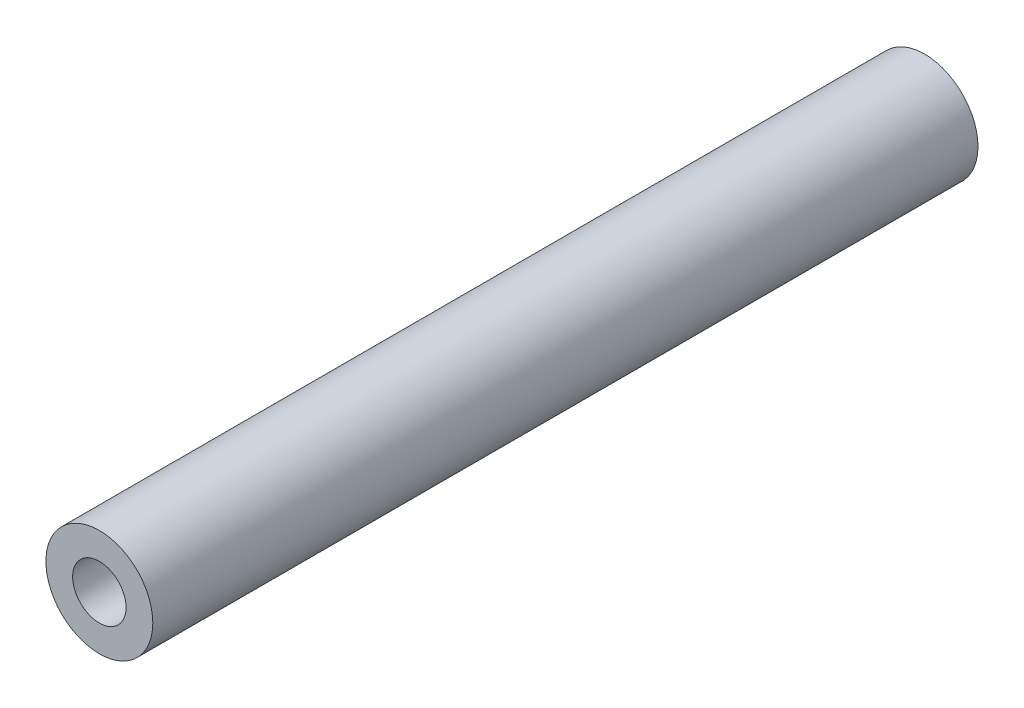
from build123d import *

# Parameters (mm, degrees)
SKETCH_6_R               = 2.5
EXTRUDE_2_DEPTH          = 19.3
M3X0_5_3_D               = 2.5
M3X0_5_3_DEPTH           = 8.5
M3X0_5_3_TIP             = 0.751075774
M3X0_5_3_ON_FACE_2_D     = 2.5
M3X0_5_3_ON_FACE_2_DEPTH = 8.5
M3X0_5_3_ON_FACE_2_TIP   = 0.751075774


with BuildPart() as part:
    # ｽｹｯﾁ6 → ﾎﾞｽ - 押し出し2 (new body, symmetric)
    with BuildSketch(Plane.XY):
        Circle(SKETCH_6_R)
    extrude(amount=EXTRUDE_2_DEPTH, both=True)

    # M3x0.5 ねじ穴3
    with Locations(Plane.XY.offset(19.3)):
        with Locations((0, 0)):
            Hole(M3X0_5_3_D / 2, depth=M3X0_5_3_DEPTH)
            with Locations((0, 0, -(M3X0_5_3_DEPTH + M3X0_5_3_TIP / 2))):  # 118° drill point
                Cone(0, M3X0_5_3_D / 2, M3X0_5_3_TIP, mode=Mode.SUBTRACT)

    # M3x0.5 ねじ穴3 on face 2
    with Locations(Plane(origin=(0, 0, -19.3), x_dir=(-1, 0, 0), z_dir=(0, 0, -1))):
        with Locations((0, 0)):
            Hole(M3X0_5_3_ON_FACE_2_D / 2, depth=M3X0_5_3_ON_FACE_2_DEPTH)
            with Locations((0, 0, -(M3X0_5_3_ON_FACE_2_DEPTH + M3X0_5_3_ON_FACE_2_TIP / 2))):  # 118° drill point
                Cone(0, M3X0_5_3_ON_FACE_2_D / 2, M3X0_5_3_ON_FACE_2_TIP, mode=Mode.SUBTRACT)


solid = part.part
